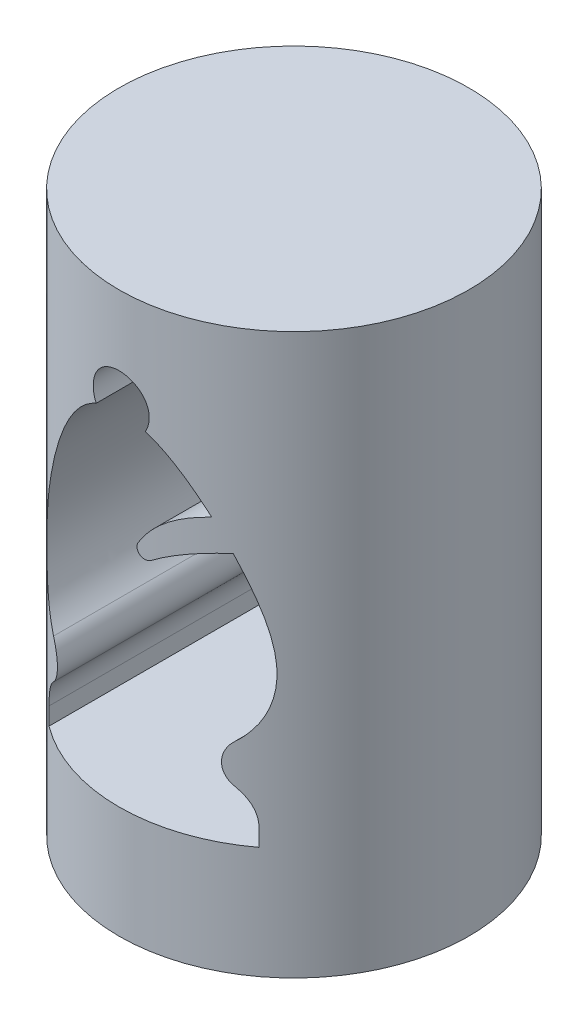
from build123d import *

# Parameters (mm, degrees)
SKETCH2_R               = 12.5
BOSS_EXTRUDE1_DEPTH     = 20
CUT_EXTRUDE1_DEPTH      = 13.5
CUT_EXTRUDE1_DEPTH_BACK = 13.5
SKETCH4_R               = 3
CUT_EXTRUDE2_DEPTH      = 3


with BuildPart() as part:
    # Sketch2 → Boss-Extrude1 (new body, symmetric)
    with BuildSketch(Plane(origin=(0, 0, 0), x_dir=(1, 0, 0), z_dir=(0, 1, 0))):
        Circle(SKETCH2_R)
    extrude(amount=BOSS_EXTRUDE1_DEPTH, both=True)

    # Sketch3 → Cut-Extrude1 (cut, two sides)
    with BuildSketch(Plane.XY) as cut_extrude1_sk:
        with BuildLine():
            Line((-7.5, -12), (7.5, -12))
            Line((7.5, -12), (7.5, -10.75))
            ThreePointArc((7.5, -10.75), (7.229985685, -9.458141194), (6.465151267, -8.38257845))
            ThreePointArc((6.465151267, -8.38257845), (5.860943971, -6.976529652), (6.5, -5.585973264))
            add(Edge.make_bspline(
                [(6.399106832, 6.007513462), (6.674880251, 5.37945403), (8.419258071, 0.928997207), (8.866568078, -3.503239262), (6.5, -5.585973264)],
                knots=[0.721905241, 0.721905241, 0.721905241, 0.721905241, 0.762107282, 1, 1, 1, 1], degree=3))
            ThreePointArc((6.399106832, 6.007513462), (4.161846652, 5.358127462), (2.124976719, 4.227554084))
            ThreePointArc((2.124976719, 4.227554084), (1.410783073, 4.270418303), (1.30152237, 4.977505287))
            ThreePointArc((1.30152237, 4.977505287), (3.037185837, 6.920492718), (5.400514483, 8.017035255))
            add(Edge.make_bspline(
                [(1.754727772, 12.040348789), (3.097405823, 11.396858203), (4.352310199, 9.878271217), (5.400514483, 8.017035255)],
                knots=[0.547214619, 0.547214619, 0.547214619, 0.547214619, 0.67737121, 0.67737121, 0.67737121, 0.67737121], degree=3))
            ThreePointArc((1.754727772, 12.040348789), (0, 15), (-1.754727772, 12.040348789))
            add(Edge.make_bspline(
                [(-6.5, -5.585973264), (-9.280086296, -3.139316304), (-7.648890565, 3.398221212), (-3.956299658, 10.941083142), (-1.754727772, 12.040348789)],
                knots=[0, 0, 0, 0, 0.237892718, 0.453262832, 0.453262832, 0.453262832, 0.453262832], degree=3))
            ThreePointArc((-6.5, -5.585973264), (-5.860943971, -6.976529652), (-6.465151267, -8.38257845))
            ThreePointArc((-6.465151267, -8.38257845), (-7.229985685, -9.458141194), (-7.5, -10.75))
            Line((-7.5, -10.75), (-7.5, -12))
        make_face()
    extrude(amount=CUT_EXTRUDE1_DEPTH, mode=Mode.SUBTRACT)
    extrude(cut_extrude1_sk.sketch, amount=-CUT_EXTRUDE1_DEPTH_BACK, mode=Mode.SUBTRACT)

    # Sketch4 → Cut-Extrude2 (cut)
    with BuildSketch(Plane(origin=(0, -20, 0), x_dir=(-1, 0, 0), z_dir=(0, -1, 0))):
        Circle(SKETCH4_R)
    extrude(amount=-CUT_EXTRUDE2_DEPTH, mode=Mode.SUBTRACT)


solid = part.part
